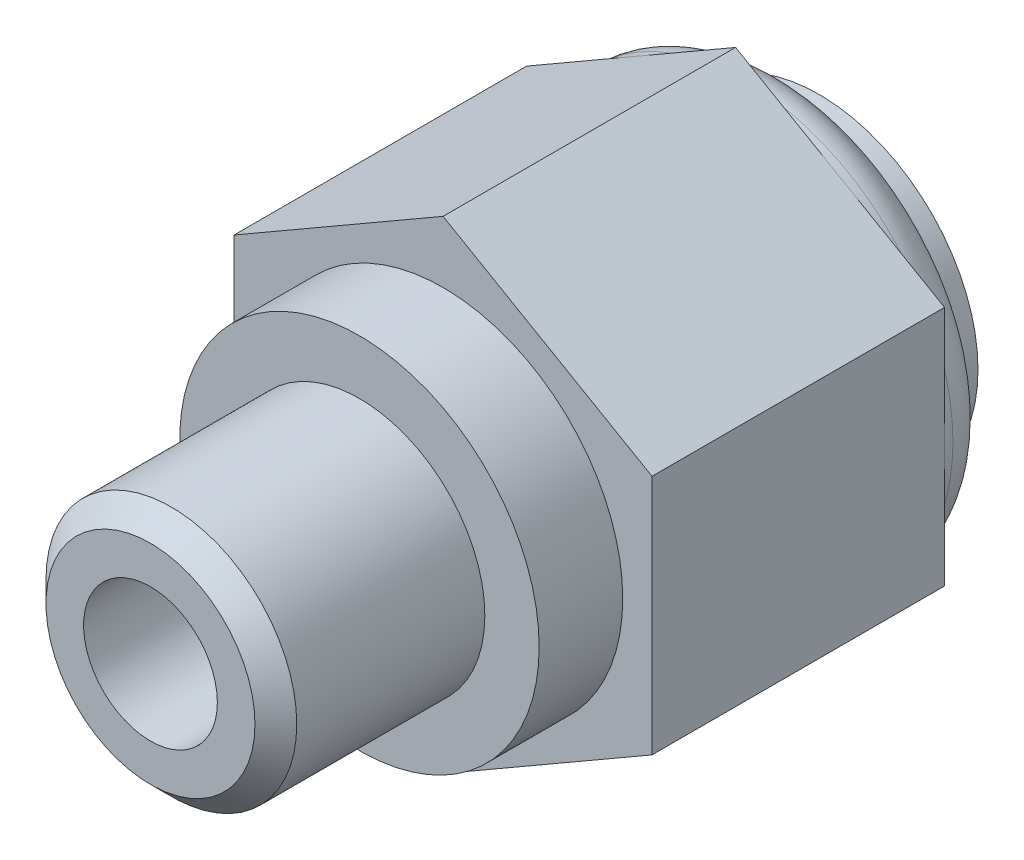
from build123d import *

# Parameters (mm, degrees)
EXTRUDE_2_DEPTH      = 7
SKETCH_1_4_R         = 5
EXTRUDE_3_DEPTH      = 1.2
SKETCH_1_5_R         = 3
EXTRUDE_4_DEPTH      = 14
SKETCH_1_6_R         = 4.3
EXTRUDE_5_DEPTH      = 9
SKETCH_1_8_R         = 3.8
EXTRUDE_6_DEPTH      = 2
FILLET_1_R           = 1
CUT_EXTRUDE_START    = -2
SKETCH_1_10_R        = 1.6
CUT_EXTRUDE_31_DEPTH = 17
SKETCH_1_11_R        = 3
SKETCH_1_11_R_2      = 1.6
CUT_EXTRUDE_32_DEPTH = 7
CHAMFER_1_SIZE       = 0.5


with BuildPart() as part:
    # Эскиз1 → Бобышка-Вытянуть2 (new body)
    with BuildSketch(Plane.XY):
        Polygon((0, 5.773502692), (-5, 2.886751346), (-5, -2.886751346), (0, -5.773502692), (5, -2.886751346), (5, 2.886751346), align=None)
    extrude(amount=EXTRUDE_2_DEPTH)

    # Эскиз1<4> → Бобышка-Вытянуть3 (add)
    with BuildSketch(Plane.XY):
        Circle(SKETCH_1_4_R)
    extrude(amount=-EXTRUDE_3_DEPTH)

    # Эскиз1<5> → Бобышка-Вытянуть4 (add)
    with BuildSketch(Plane.XY):
        Circle(SKETCH_1_5_R)
    extrude(amount=EXTRUDE_4_DEPTH)

    # Эскиз1<6> → Бобышка-Вытянуть5 (add)
    with BuildSketch(Plane.XY):
        Circle(SKETCH_1_6_R)
    extrude(amount=EXTRUDE_5_DEPTH)

    # Эскиз1<8> → Бобышка-Вытянуть6 (add)
    with BuildSketch(Plane.XY):
        Circle(SKETCH_1_8_R)
    extrude(amount=-EXTRUDE_6_DEPTH)

    # Скругление1
    fillet_1_edges = [part.edges().sort_by_distance(p)[0] for p in [
        (-5, 0, -1.2),
    ]]
    fillet(fillet_1_edges, radius=FILLET_1_R)

    # Эскиз1<10> → Вырез-Вытянуть31 (cut, through all)
    with BuildSketch(Plane.XY.offset(CUT_EXTRUDE_START)):
        Circle(SKETCH_1_10_R)
    extrude(amount=CUT_EXTRUDE_31_DEPTH, mode=Mode.SUBTRACT)

    # Эскиз1<11> → Вырез-Вытянуть32 (cut)
    with BuildSketch(Plane.XY.offset(CUT_EXTRUDE_START)):
        Circle(SKETCH_1_11_R)
        Circle(SKETCH_1_11_R_2, mode=Mode.SUBTRACT)
    extrude(amount=CUT_EXTRUDE_32_DEPTH, mode=Mode.SUBTRACT)

    # Фаска1
    chamfer_1_edges = [part.edges().sort_by_distance(p)[0] for p in [
        (-3, 0, 14),
    ]]
    chamfer(chamfer_1_edges, length=CHAMFER_1_SIZE)


solid = part.part
